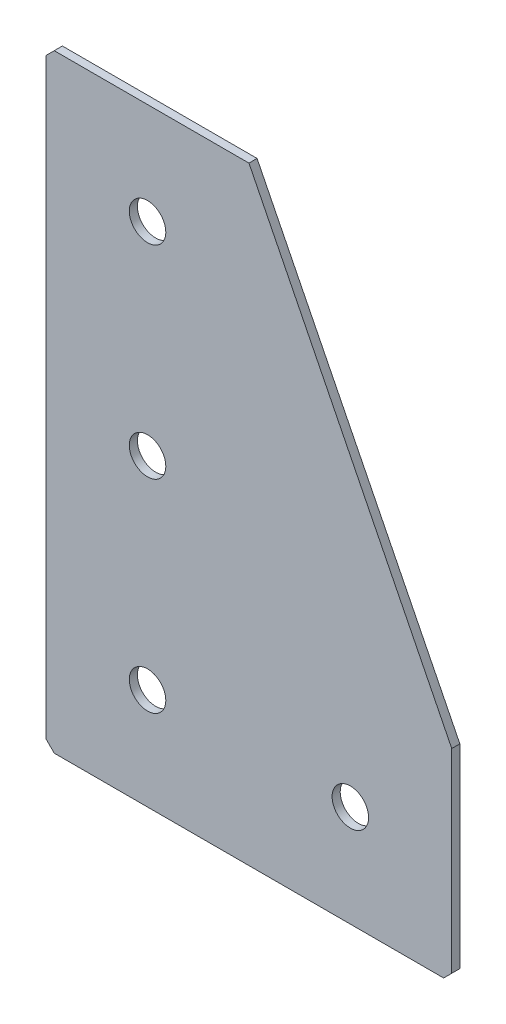
from build123d import *

# Parameters (mm, degrees)
EXTRUDE_1_DEPTH   = 2
HOLE_WIZARD_M81_D = 9
CHAMFER_1_SIZE    = 2


with BuildPart() as part:
    # Эскиз1 → Бобышка-Вытянуть1 (new body)
    with BuildSketch(Plane(origin=(0, 0, 0), x_dir=(1, 0, 0), z_dir=(0, 0, -1))):
        Polygon((0, 0), (0, 150), (100, 150), (100, 100), (50, 0), align=None)
    extrude(amount=EXTRUDE_1_DEPTH)

    # Отверстие с зазором M81 (through all)
    with Locations(Plane(origin=(0, 0, -2), x_dir=(1, 0, 0), z_dir=(0, 0, -1))):
        with Locations((75, 125), (25, 125), (25, 75), (25, 25)):
            Hole(HOLE_WIZARD_M81_D / 2)

    # Фаска1
    chamfer_1_edges = [part.edges().sort_by_distance(p)[0] for p in [
        (0, 0, -1),
        (0, -150, -1),
        (100, -150, -1),
    ]]
    chamfer(chamfer_1_edges, length=CHAMFER_1_SIZE)


solid = part.part
